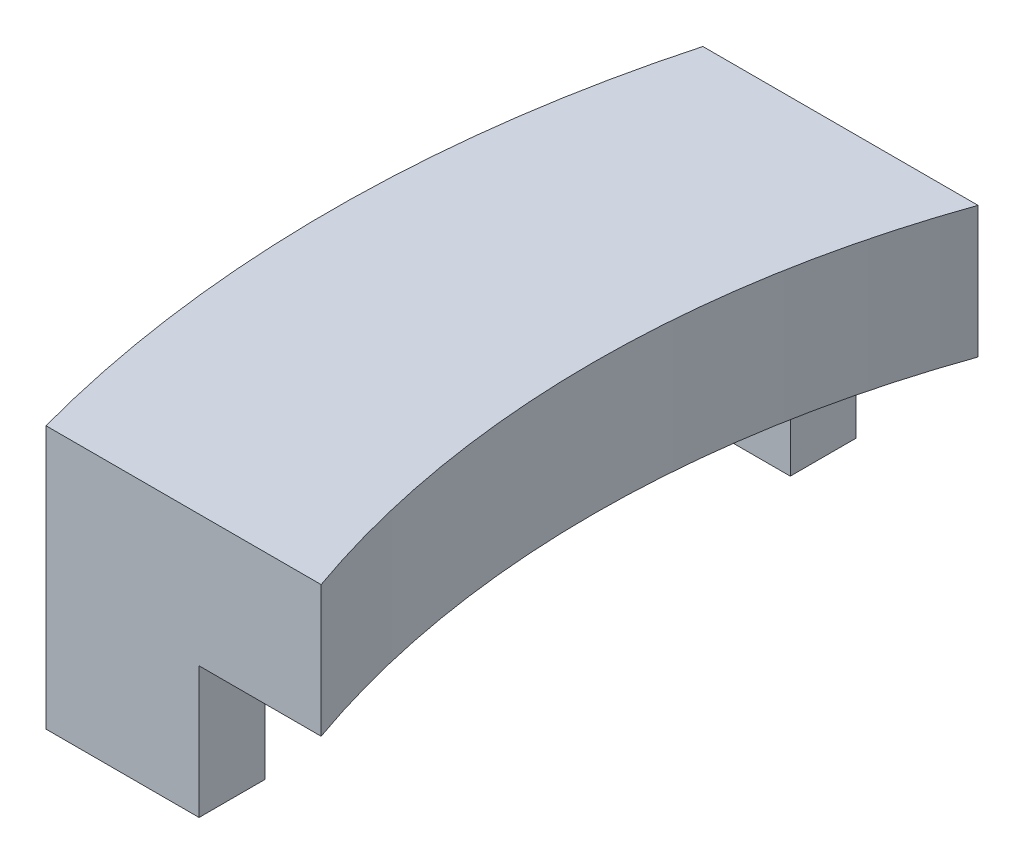
from build123d import *

# Parameters (mm, degrees)
BOSS_EXTRUDE1_DEPTH = 2
BOSS_EXTRUDE2_DEPTH = 2


with BuildPart() as part:
    # Sketch1 → Boss-Extrude1 (new body)
    with BuildSketch(Plane(origin=(0, 0, 0), x_dir=(1, 0, 0), z_dir=(0, 1, 0))):
        with BuildLine():
            Line((-18.33030278, 5), (-14.142135624, 5))
            ThreePointArc((-14.142135624, 5), (-15, 0), (-14.142135624, -5))
            Line((-14.142135624, -5), (-18.33030278, -5))
            ThreePointArc((-18.33030278, -5), (-19, 0), (-18.33030278, 5))
        make_face()
    extrude(amount=BOSS_EXTRUDE1_DEPTH)

    # Sketch2 → Boss-Extrude2 (add)
    with BuildSketch(Plane.XZ):
        with BuildLine():
            Line((-16, -5), (-18.33030278, -5))
            ThreePointArc((-18.33030278, -5), (-18.459012203, -4.501651751), (-18.574175621, -4))
            Line((-18.574175621, -4), (-16, -4))
            Line((-16, -4), (-16, -5))
        make_face()
        with BuildLine():
            Line((-18.33030278, 5), (-16, 5))
            Line((-16, 5), (-16, 4))
            Line((-16, 4), (-18.574175621, 4))
            ThreePointArc((-18.574175621, 4), (-18.459012203, 4.501651751), (-18.33030278, 5))
        make_face()
    extrude(amount=BOSS_EXTRUDE2_DEPTH)


solid = part.part
